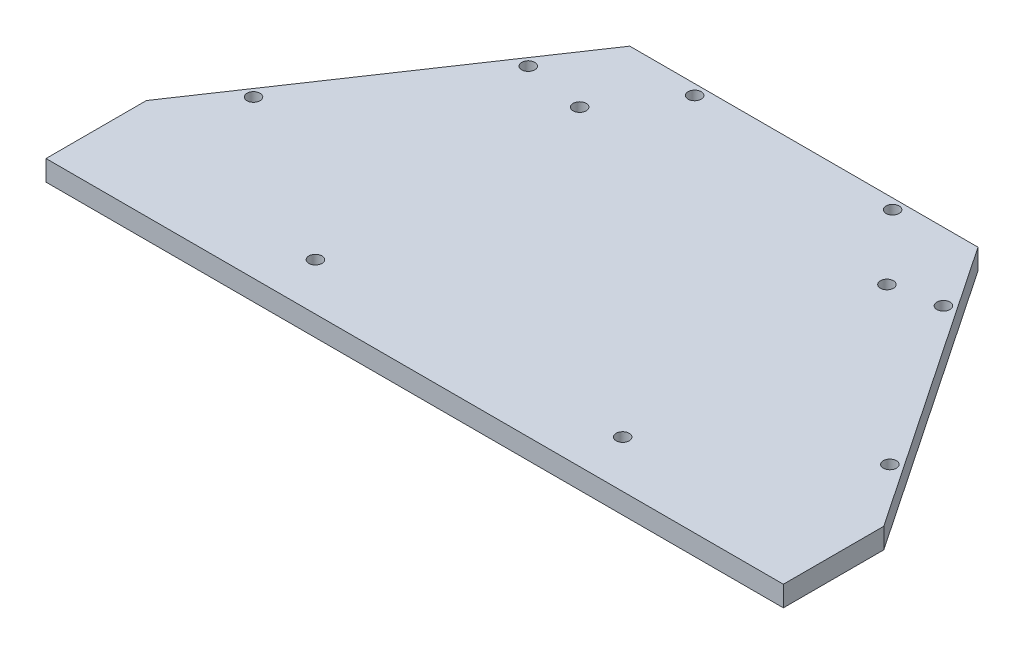
from build123d import *

# Parameters (mm, degrees)
BOSS_EXTRUDE1_DEPTH = 5
SKETCH2_R           = 1.6
CUT_EXTRUDE1_DEPTH  = 10
SKETCH3_R           = 1.6
CUT_EXTRUDE2_DEPTH  = 13
SKETCH5_R           = 2.8
CUT_EXTRUDE3_DEPTH  = 1
SKETCH4_R           = 2.8
CUT_EXTRUDE4_DEPTH  = 1


with BuildPart() as part:
    # Sketch1 → Boss-Extrude1 (new body)
    with BuildSketch(Plane(origin=(0, 0, 0), x_dir=(1, 0, 0), z_dir=(0, 1, 0))):
        Polygon((44.733199147, 23.708961101), (-40.266800853, 23.708961101), (-87.761294074, -46.784110287), (-87.761294074, -71.294110287), (92.227692368, -71.294110287), (92.227692368, -46.784110287), align=None)
    extrude(amount=BOSS_EXTRUDE1_DEPTH)

    # Sketch2 → Cut-Extrude1 (cut)
    with BuildSketch(Plane(origin=(0, 5, 0), x_dir=(1, 0, 0), z_dir=(0, 1, 0))):
        with Locations((-21.927484651, 21.208961101)):
            Circle(SKETCH2_R)
        with Locations((26.393882946, 21.208961101)):
            Circle(SKETCH2_R)
        with Locations((-48.443257362, 7.098961101)):
            Circle(SKETCH2_R)
        with Locations((-75.438186307, -32.967904005)):
            Circle(SKETCH2_R)
        with Locations((52.909655656, 7.098961101)):
            Circle(SKETCH2_R)
        with Locations((79.904584601, -32.967904005)):
            Circle(SKETCH2_R)
    extrude(amount=-CUT_EXTRUDE1_DEPTH, mode=Mode.SUBTRACT)

    # Sketch3 → Cut-Extrude2 (cut)
    with BuildSketch(Plane(origin=(0, 5, 0), x_dir=(1, 0, 0), z_dir=(0, 1, 0))):
        with Locations((-33.49256942, 4.708961101)):
            Circle(SKETCH3_R)
        with Locations((41.50743058, 4.708961101)):
            Circle(SKETCH3_R)
        with Locations((41.50743058, -59.791038899)):
            Circle(SKETCH3_R)
        with Locations((-33.49256942, -59.791038899)):
            Circle(SKETCH3_R)
    extrude(amount=-CUT_EXTRUDE2_DEPTH, mode=Mode.SUBTRACT)

    # Sketch5 → Cut-Extrude3 (cut)
    with BuildSketch(Plane(origin=(0, 0, 0), x_dir=(-1, 0, 0), z_dir=(0, -1, 0))):
        with Locations((33.49256942, 4.708961101)):
            Circle(SKETCH5_R)
        with Locations((33.49256942, -59.791038899)):
            Circle(SKETCH5_R)
        with Locations((-41.50743058, -59.791038899)):
            Circle(SKETCH5_R)
    extrude(amount=-CUT_EXTRUDE3_DEPTH, mode=Mode.SUBTRACT)

    # Sketch4 → Cut-Extrude4 (cut)
    with BuildSketch(Plane.XZ):
        with Locations((41.50743058, -4.708961101)):
            Circle(SKETCH4_R)
    extrude(amount=-CUT_EXTRUDE4_DEPTH, mode=Mode.SUBTRACT)


solid = part.part
